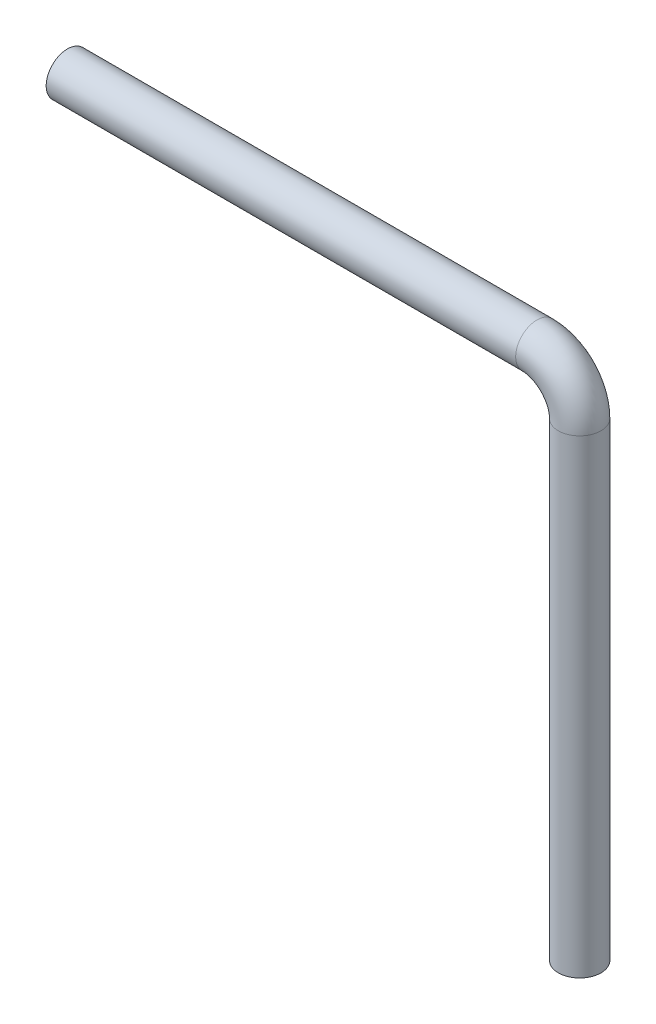
from build123d import *

# Parameters (mm, degrees)
SKETCH2_R = 5


with BuildPart() as part:
    # Sweep1: sweep along a path in Sketch1
    with BuildLine(Plane.XY) as sweep1_path:
        Line((-120, 0), (-10, 0))
        ThreePointArc((-10, 0), (-2.928932188, -2.928932188), (0, -10))
        Line((0, -10), (0, -120))
    # Sketch2 → Sweep1 (sweep)
    with BuildSketch(Plane(origin=(0, -120, 0), x_dir=(1, 0, 0), z_dir=(0, 1, 0))):
        Circle(SKETCH2_R)
    sweep(path=sweep1_path.line)


solid = part.part
